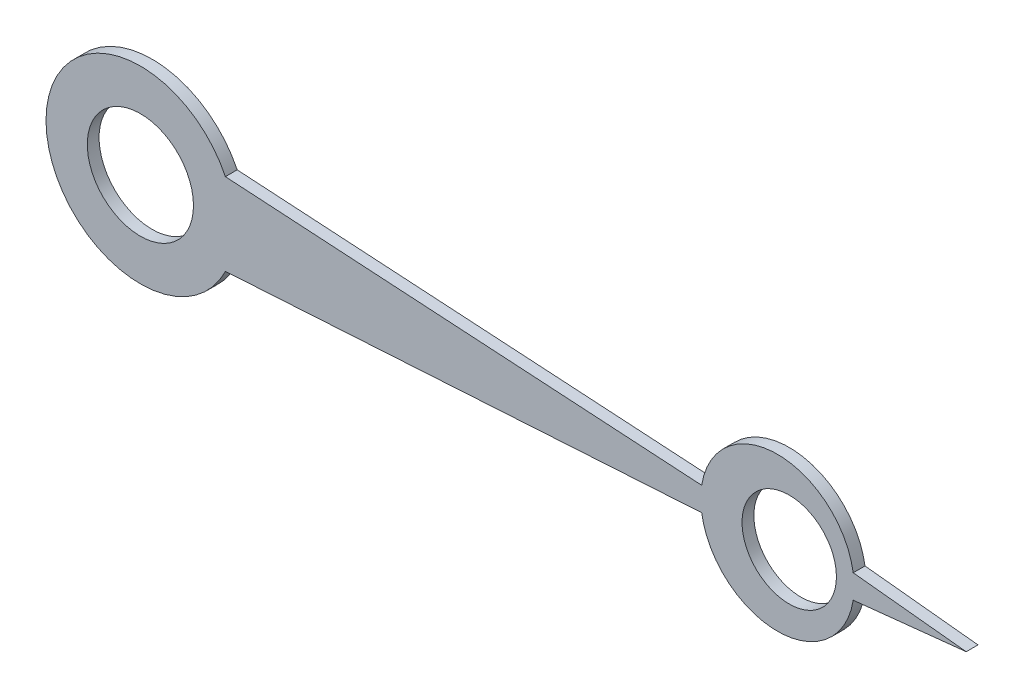
from build123d import *

# Parameters (mm, degrees)
BOSS_EXTRUDE1_START = 19
SKETCH1_R           = 4
SKETCH1_R_2         = 4.5
BOSS_EXTRUDE1_DEPTH = 1


with BuildPart() as part:
    # Sketch1 → Boss-Extrude1 (new body)
    with BuildSketch(Plane.XY.offset(BOSS_EXTRUDE1_START)):
        with BuildLine():
            Line((60.421564163, 1.006734174), (70, 0))
            Line((70, 0), (60.421564163, -1.006734174))
            ThreePointArc((60.421564163, -1.006734174), (54, -6.5), (47.578435837, -1.006734174))
            Line((47.578435837, -1.006734174), (7.205346635, -3.476058093))
            ThreePointArc((7.205346635, -3.476058093), (-8, 0), (7.205346635, 3.476058093))
            Line((7.205346635, 3.476058093), (47.578435837, 1.006734174))
            ThreePointArc((47.578435837, 1.006734174), (54, 6.5), (60.421564163, 1.006734174))
        make_face()
        with Locations((55, 0)):
            Circle(SKETCH1_R, mode=Mode.SUBTRACT)
        Circle(SKETCH1_R_2, mode=Mode.SUBTRACT)
    extrude(amount=BOSS_EXTRUDE1_DEPTH)


solid = part.part
